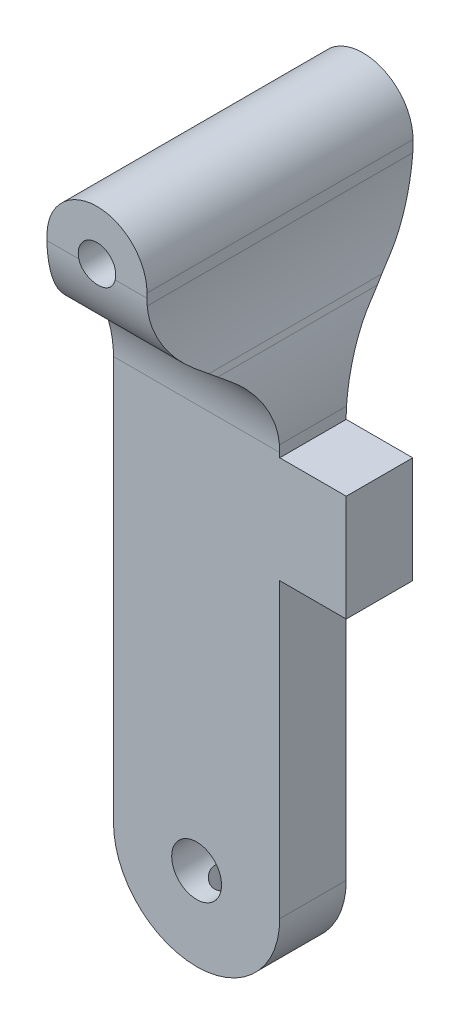
from build123d import *

# Parameters (mm, degrees)
SKETCH1_W               = 22.225
SKETCH1_H               = 67.6402
BOSS_EXTRUDE1_DEPTH     = 25.4
SKETCH2_R               = 1.7907
CUT_EXTRUDE2_DEPTH      = 25.4
SKETCH4_W               = 9.525
SKETCH4_H               = 10.16
SKETCH4_H_2             = 35.894850391
SKETCH4_H_3             = 35.916644849
CUT_EXTRUDE3_DEPTH      = 51.712797865
SKETCH5_R               = 2.38125
CUT_EXTRUDE4_DEPTH      = 6.35
CUT_EXTRUDE5_REACH      = 79.582
CUT_EXTRUDE5_END_RADIUS = 2.38125
SKETCH6_R               = 1.455475959


with BuildPart() as part:
    # Sketch1 → Boss-Extrude1 (new body)
    with BuildSketch(Plane.XY):
        with Locations((-17.147623967, 4.03062314)):
            Rectangle(SKETCH1_W, SKETCH1_H)
    extrude(amount=BOSS_EXTRUDE1_DEPTH)

    # Sketch2 → Cut-Extrude2 (cut)
    with BuildSketch(Plane.XY.offset(25.4)):
        with BuildLine():
            ThreePointArc((-20.309923967, 37.85072314), (-16.933347665, 36.452099442), (-15.534723967, 33.07552314))
            Line((-15.534723967, 33.07552314), (-15.534723967, 31.988846816))
            ThreePointArc((-15.534723967, 31.988846816), (-15.164047916, 28.377221194), (-14.067475414, 24.916185349))
            Line((-14.067475414, 24.916185349), (-13.85237252, 24.420060932))
            ThreePointArc((-13.85237252, 24.420060932), (-12.755800018, 20.959025087), (-12.385123967, 17.347399465))
            Line((-12.385123967, 17.347399465), (-12.385123967, 16.26072314))
            Line((-12.385123967, 16.26072314), (-6.035123967, 16.26072314))
            Line((-6.035123967, 16.26072314), (-6.035123967, 37.85072314))
            Line((-6.035123967, 37.85072314), (-20.309923967, 37.85072314))
        make_face()
        with BuildLine():
            Line((-25.085123967, 32.016111722), (-25.085123967, 33.07552314))
            ThreePointArc((-25.085123967, 33.07552314), (-23.686500268, 36.452099442), (-20.309923967, 37.85072314))
            Line((-20.309923967, 37.85072314), (-28.260123967, 37.85072314))
            Line((-28.260123967, 37.85072314), (-28.260123967, 17.320134559))
            ThreePointArc((-28.260123967, 17.320134559), (-27.884120973, 20.957343409), (-26.772015056, 24.440716329))
            Line((-26.772015056, 24.440716329), (-26.573232878, 24.895529952))
            ThreePointArc((-26.573232878, 24.895529952), (-25.461126961, 28.378902872), (-25.085123967, 32.016111722))
        make_face()
        with BuildLine():
            Line((-6.035123967, -29.78947686), (-6.035123967, 6.10072314))
            Line((-6.035123967, 6.10072314), (-12.385123967, 6.10072314))
            Line((-12.385123967, 6.10072314), (-12.385123967, -21.85197686))
            ThreePointArc((-12.385123967, -21.85197686), (-14.709963891, -27.464636935), (-20.322623967, -29.78947686))
            Line((-20.322623967, -29.78947686), (-6.035123967, -29.78947686))
        make_face()
        with BuildLine():
            ThreePointArc((-20.322623967, -29.78947686), (-25.935284043, -27.464636935), (-28.260123967, -21.85197686))
            Line((-28.260123967, -21.85197686), (-28.260123967, -29.78947686))
            Line((-28.260123967, -29.78947686), (-20.322623967, -29.78947686))
        make_face()
        with Locations((-20.309923967, 33.07552314)):
            Circle(SKETCH2_R)
    extrude(amount=-CUT_EXTRUDE2_DEPTH, mode=Mode.SUBTRACT)

    # Sketch4 → Cut-Extrude3 (cut, through all)
    with BuildSketch(Plane(origin=(-6.035123967, 0, 0), x_dir=(0, 0, -1), z_dir=(1, 0, 0))):
        with BuildLine():
            Line((-9.525, 16.698464592), (-9.525, 16.26072314))
            Line((-9.525, 16.26072314), (0, 16.26072314))
            Line((0, 16.26072314), (0, 32.637781689))
            ThreePointArc((0, 32.637781689), (-0.909409772, 28.750457477), (-3.448884978, 25.669973531))
            Line((-3.448884978, 25.669973531), (-6.076115022, 23.66627275))
            ThreePointArc((-6.076115022, 23.66627275), (-8.615590228, 20.585788804), (-9.525, 16.698464592))
        make_face()
        with Locations((-4.7625, 11.18072314)):
            Rectangle(SKETCH4_W, SKETCH4_H)
        with Locations((-4.7625, -11.846702056)):
            Rectangle(SKETCH4_W, SKETCH4_H_2)
        with Locations((-20.6375, -11.857599285)):
            Rectangle(SKETCH4_W, SKETCH4_H_3)
        with Locations((-20.6375, 11.18072314)):
            Rectangle(SKETCH4_W, SKETCH4_H)
        with BuildLine():
            Line((-25.4, 16.26072314), (-15.875, 16.26072314))
            Line((-15.875, 16.26072314), (-15.875, 16.698464592))
            ThreePointArc((-15.875, 16.698464592), (-16.784409772, 20.585788804), (-19.323884978, 23.66627275))
            Line((-19.323884978, 23.66627275), (-21.951115022, 25.669973531))
            ThreePointArc((-21.951115022, 25.669973531), (-24.490590228, 28.750457477), (-25.4, 32.637781689))
            Line((-25.4, 32.637781689), (-25.4, 16.26072314))
        make_face()
    extrude(amount=-CUT_EXTRUDE3_DEPTH, mode=Mode.SUBTRACT)

    # Sketch5 → Cut-Extrude4 (cut)
    with BuildSketch(Plane(origin=(0, 0, 9.525), x_dir=(-1, 0, 0), z_dir=(0, 0, -1))):
        with Locations((20.322623967, -21.85197686)):
            Circle(SKETCH5_R)
    extrude(amount=-CUT_EXTRUDE4_DEPTH, mode=Mode.SUBTRACT)

    # Cut-Extrude5: up to this cylinder (the profile starts outside it)
    cut_extrude5_end = Plane(origin=(-20.322623967, -21.85197686, 12.7), z_dir=(0, 0, -1)) * Cylinder(CUT_EXTRUDE5_END_RADIUS, 164.9265, mode=Mode.PRIVATE)
    # Sketch6 → Cut-Extrude5 (cut, up to the surface)
    with BuildSketch(Plane.XZ.offset(29.78947686), mode=Mode.PRIVATE) as cut_extrude5_sk1:
        with Locations((-20.322623967, 12.7)):
            Circle(SKETCH6_R)
    cut_extrude5_tool1 = extrude(cut_extrude5_sk1.sketch, amount=-CUT_EXTRUDE5_REACH, mode=Mode.PRIVATE) - cut_extrude5_end
    add(cut_extrude5_tool1.solids().sort_by_distance((-20.322624, -29.789477, 12.7))[0], mode=Mode.SUBTRACT)


solid = part.part
